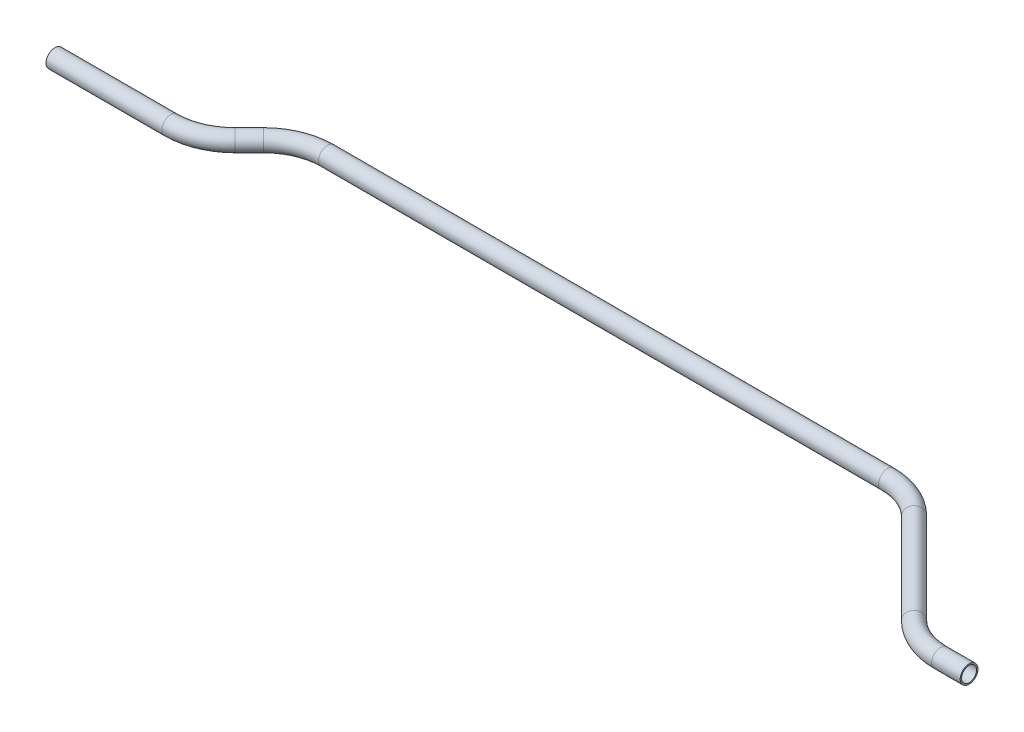
from build123d import *

# Parameters (mm, degrees)
SKETCH2_R   = 7.9375
SKETCH2_R_2 = 6.6929


with BuildPart() as part:
    # Sweep1: sweep along a path in Sketch1
    with BuildLine(Plane(origin=(0, 0, 0), x_dir=(1, 0, 0), z_dir=(0, 1, 0))) as sweep1_path:
        Line((0, 0), (103.32769491, 0))
        ThreePointArc((103.32769491, 0), (125.19805307, 4.350284717), (143.738847455, 16.738847455))
        Line((143.738847455, 16.738847455), (156.405011336, 29.405011336))
        ThreePointArc((156.405011336, 29.405011336), (174.945805722, 41.793574075), (196.816163881, 46.143858792))
        Line((196.816163881, 46.143858792), (696.031788612, 46.143858792))
        ThreePointArc((696.031788612, 46.143858792), (717.902146772, 41.793574075), (736.442941157, 29.405011336))
        Line((736.442941157, 29.405011336), (817.265246247, -51.417293753))
        ThreePointArc((817.265246247, -51.417293753), (835.806040632, -63.805856491), (857.676398792, -68.156141208))
        Line((857.676398792, -68.156141208), (883.076398792, -68.156141208))
    # Sketch2 → Sweep1 (sweep)
    with BuildSketch(Plane(origin=(0, 0, 0), x_dir=(0, 0, -1), z_dir=(1, 0, 0))):
        Circle(SKETCH2_R)
        Circle(SKETCH2_R_2, mode=Mode.SUBTRACT)
    sweep(path=sweep1_path.line)


solid = part.part
